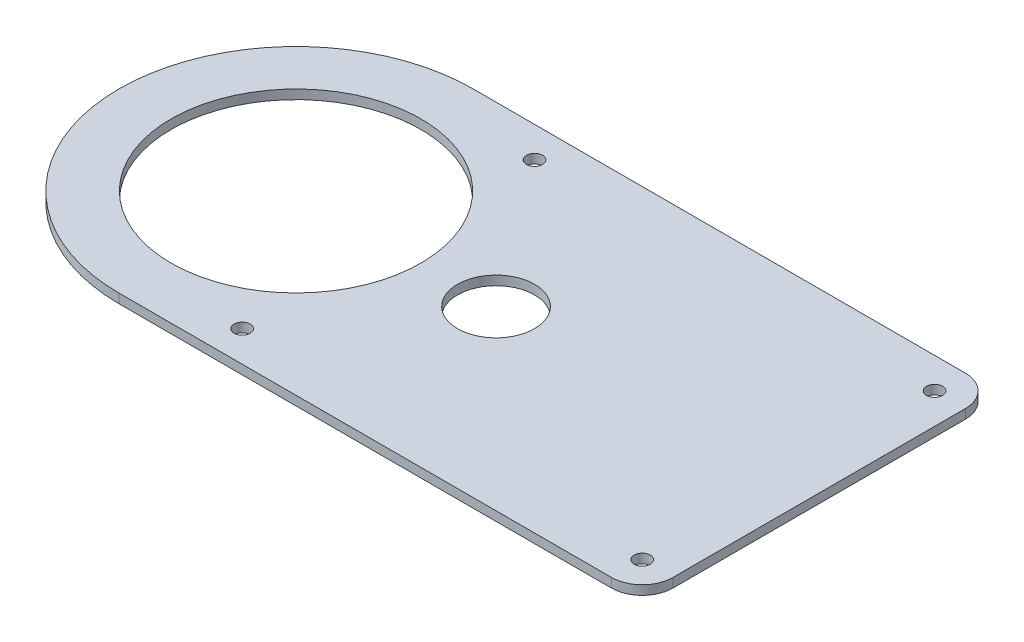
from build123d import *

# Parameters (mm, degrees)
SKETCH1_R           = 57.5
SKETCH1_R_2         = 40.6
BOSS_EXTRUDE1_DEPTH = 3
FILLET1_R           = 10
SKETCH2_R           = 2.6
SKETCH2_R_2         = 12.5
CUT_EXTRUDE1_DEPTH  = 4


with BuildPart() as part:
    # Sketch1 → Boss-Extrude1 (new body)
    with BuildSketch(Plane(origin=(0, 0, 0), x_dir=(1, 0, 0), z_dir=(0, 1, 0))):
        with BuildLine():
            Line((170, 57.5), (0, 57.5))
            ThreePointArc((0, 57.5), (40.658639918, 40.658639918), (57.5, 0))
            ThreePointArc((57.5, 0), (40.658639918, -40.658639918), (0, -57.5))
            Line((0, -57.5), (170, -57.5))
            Line((170, -57.5), (170, 57.5))
        make_face()
        Circle(SKETCH1_R)
        Circle(SKETCH1_R_2, mode=Mode.SUBTRACT)
    extrude(amount=BOSS_EXTRUDE1_DEPTH)

    # Fillet1
    fillet1_edges = [part.edges().sort_by_distance(p)[0] for p in [
        (170, 1.5, -57.5),
        (170, 1.5, 57.5),
    ]]
    fillet(fillet1_edges, radius=FILLET1_R)

    # Sketch2 → Cut-Extrude1 (cut, through all)
    with BuildSketch(Plane(origin=(0, 3, 0), x_dir=(1, 0, 0), z_dir=(0, 1, 0))):
        with Locations((160, 47.5)):
            Circle(SKETCH2_R)
        with Locations((160, -47.5)):
            Circle(SKETCH2_R)
        with Locations((30, -47.5)):
            Circle(SKETCH2_R)
        with Locations((30, 47.5)):
            Circle(SKETCH2_R)
        with Locations((65, 0)):
            Circle(SKETCH2_R_2)
    extrude(amount=-CUT_EXTRUDE1_DEPTH, mode=Mode.SUBTRACT)


solid = part.part
